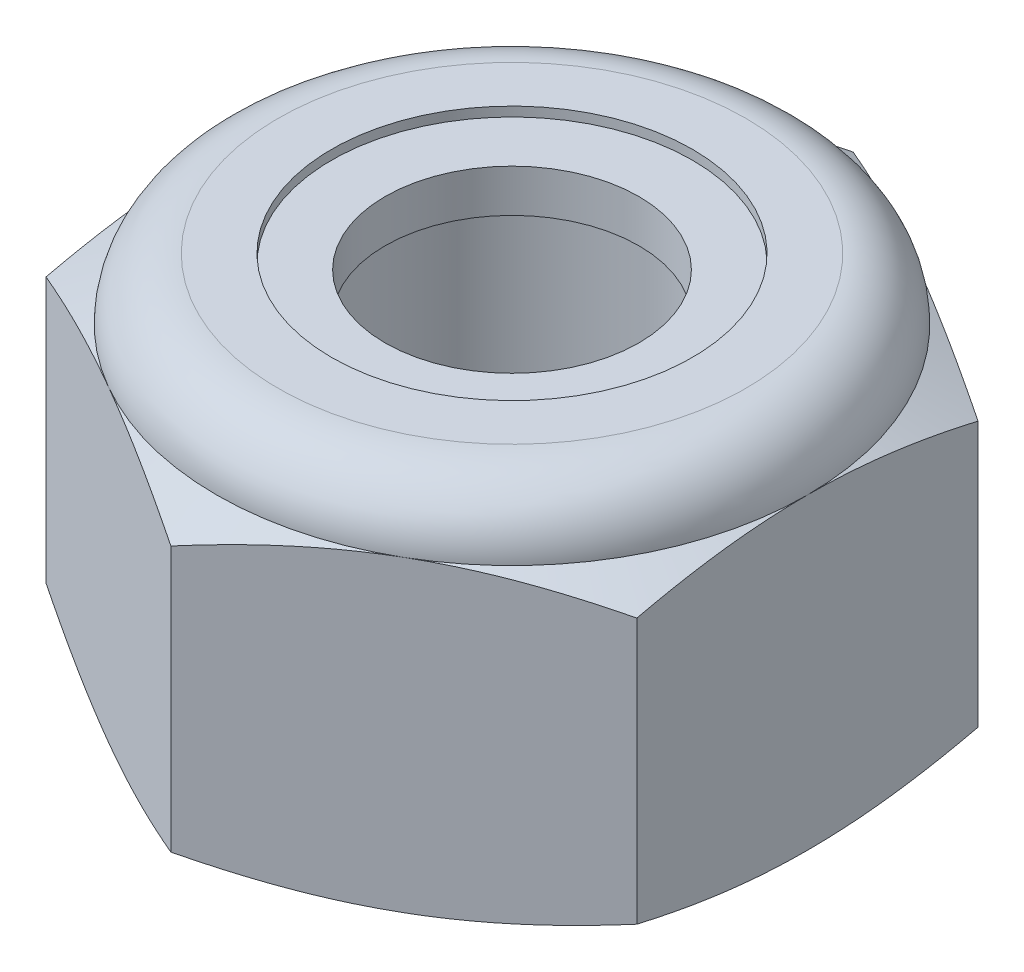
from build123d import *

# Parameters (mm, degrees)
EXTRUDE1_DEPTH = 5.953125
SKETCH2_W      = 2.413
SKETCH2_H      = 5.953125


with BuildPart() as part:
    # Sketch1 → Extrude1 (new body)
    with BuildSketch(Plane(origin=(0, 0, 0), x_dir=(1, 0, 0), z_dir=(0, 1, 0))):
        Polygon((0, 5.499261314), (-4.7625, 2.749630657), (-4.7625, -2.749630657), (0, -5.499261314), (4.7625, -2.749630657), (4.7625, 2.749630657), align=None)
    extrude(amount=EXTRUDE1_DEPTH)


with BuildPart() as body_2:
    # Sketch2 → Revolve1 (revolve)
    with BuildSketch(Plane(origin=(0, 0, 0), x_dir=(0, 0, -1), z_dir=(1, 0, 0))):
        with Locations((1.2065, 2.9765625)):
            Rectangle(SKETCH2_W, SKETCH2_H)
    revolve(axis=Axis((0, -2.413, 0), (0, 1, 0)))


with BuildPart() as part_1:
    add(part.part)

    # Combine1: cut body 2
    add(body_2.part, mode=Mode.SUBTRACT)

    # Sketch5 → Cut-Revolve3 (revolve, cut)
    with BuildSketch(Plane(origin=(0, 0, 0), x_dir=(0, 0, -1), z_dir=(1, 0, 0))):
        with BuildLine():
            Line((0, 0), (4.7625, 0))
            Line((4.7625, 0), (5.499261314, 0.343557443))
            Line((5.499261314, 0.343557443), (5.499261314, 4.617380057))
            Line((5.499261314, 4.617380057), (4.7625, 4.9609375))
            ThreePointArc((4.7625, 4.9609375), (4.471895009, 5.662520009), (3.7703125, 5.953125))
            Line((3.7703125, 5.953125), (3.7703125, 7.223125))
            Line((3.7703125, 7.223125), (6.769261314, 7.223125))
            Line((6.769261314, 7.223125), (6.769261314, -1.27))
            Line((6.769261314, -1.27), (0, -1.27))
            Line((0, -1.27), (0, 0))
        make_face()
    revolve(axis=Axis((0, 0, 0), (0, 1, 0)), mode=Mode.SUBTRACT)

    # Sketch6 → Cut-Revolve4 (revolve, cut)
    with BuildSketch(Plane(origin=(0, 0, 0), x_dir=(0, 0, -1), z_dir=(1, 0, 0))):
        with BuildLine():
            Line((0, 4.9609375), (4.6101, 4.9609375))
            ThreePointArc((4.6101, 4.9609375), (4.364131936, 5.554756936), (3.7703125, 5.800725))
            Line((3.7703125, 5.800725), (2.907868669, 5.800725))
            Line((2.907868669, 5.800725), (2.907868669, 7.223125))
            Line((2.907868669, 7.223125), (0, 7.223125))
            Line((0, 7.223125), (0, 4.9609375))
        make_face()
    revolve(axis=Axis((0, 7.223125, 0), (0, 1, 0)), mode=Mode.SUBTRACT)


with BuildPart() as body_2_2:
    # Sketch7 → Revolve2 (revolve)
    with BuildSketch(Plane(origin=(0, 0, 0), x_dir=(0, 0, -1), z_dir=(1, 0, 0))):
        with BuildLine():
            Line((2.045424837, 5.0371375), (4.530088408, 5.0371375))
            ThreePointArc((4.530088408, 5.0371375), (4.282601726, 5.527175629), (3.7703125, 5.724525))
            Line((3.7703125, 5.724525), (2.045424837, 5.724525))
            Line((2.045424837, 5.724525), (2.045424837, 5.0371375))
        make_face()
    revolve(axis=Axis((0, 5.0371375, 0), (0, 1, 0)))


solid = Compound([part_1.part, body_2_2.part])
